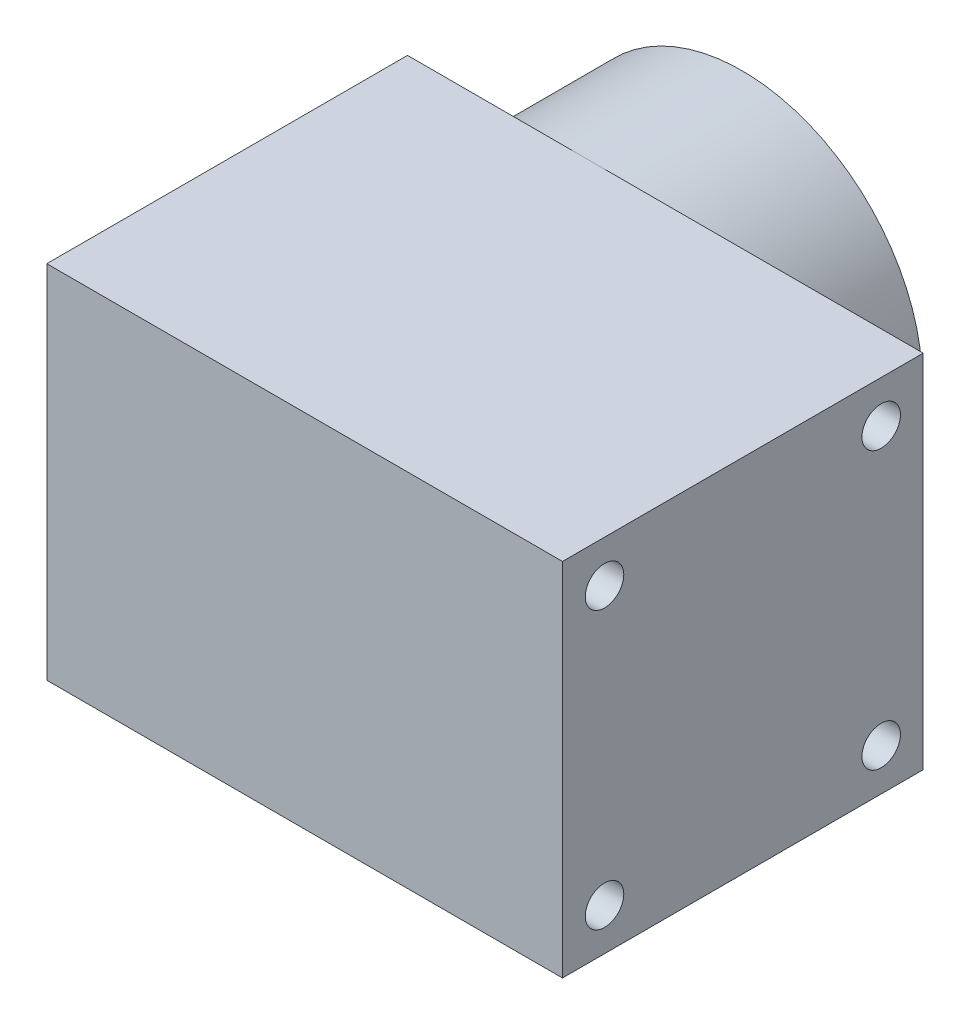
from build123d import *

# Parameters (mm, degrees)
SKETCH1_R           = 28.1
BOSS_EXTRUDE2_DEPTH = 24
CUT_EXTRUDE2_DEPTH  = 21.5
SKETCH4_R           = 3
CUT_EXTRUDE3_DEPTH  = 9.5
SKETCH6_R           = 6.025
CUT_EXTRUDE4_DEPTH  = 6.2
SKETCH7_W           = 56.2
SKETCH7_H           = 56.2
BOSS_EXTRUDE3_DEPTH = 56.2
SKETCH8_W           = 56.2
SKETCH8_H           = 56.2
BOSS_EXTRUDE4_DEPTH = 14.14
SKETCH10_W          = 56.2
SKETCH10_H          = 56.2
BOSS_EXTRUDE5_DEPTH = 10
SKETCH19_W          = 51.2
SKETCH19_H          = 51.2
CUT_EXTRUDE5_DEPTH  = 63.7
SKETCH21_R          = 3
CUT_EXTRUDE7_DEPTH  = 20


with BuildPart() as part:
    # Sketch1 → Boss-Extrude2 (new body)
    with BuildSketch(Plane.XY):
        Circle(SKETCH1_R)
    extrude(amount=BOSS_EXTRUDE2_DEPTH)

    # Sketch3 → Cut-Extrude2 (cut)
    with BuildSketch(Plane(origin=(0, 0, 0), x_dir=(-1, 0, 0), z_dir=(0, 0, -1))):
        with BuildLine():
            Line((-1.661801922, 2.5), (1.661801922, 2.5))
            ThreePointArc((1.661801922, 2.5), (0, -3.001930317), (-1.661801922, 2.5))
        make_face()
    extrude(amount=-CUT_EXTRUDE2_DEPTH, mode=Mode.SUBTRACT)

    # Sketch4 → Cut-Extrude3 (cut)
    with BuildSketch(Plane(origin=(0, 0, 0), x_dir=(-1, 0, 0), z_dir=(0, 0, -1))):
        Circle(SKETCH4_R)
    extrude(amount=-CUT_EXTRUDE3_DEPTH, mode=Mode.SUBTRACT)

    # Sketch6 → Cut-Extrude4 (cut)
    with BuildSketch(Plane(origin=(0, 0, 0), x_dir=(-1, 0, 0), z_dir=(0, 0, -1))):
        Circle(SKETCH6_R)
    extrude(amount=-CUT_EXTRUDE4_DEPTH, mode=Mode.SUBTRACT)

    # Sketch7 → Boss-Extrude3 (add)
    with BuildSketch(Plane.XY.offset(24)):
        Rectangle(SKETCH7_W, SKETCH7_H)
    extrude(amount=BOSS_EXTRUDE3_DEPTH)

    # Sketch8 → Boss-Extrude4 (add)
    with BuildSketch(Plane(origin=(28.1, 0, 0), x_dir=(0, 0, -1), z_dir=(1, 0, 0))):
        with Locations((-52.1, 0)):
            Rectangle(SKETCH8_W, SKETCH8_H)
    extrude(amount=BOSS_EXTRUDE4_DEPTH)

    # Sketch10 → Boss-Extrude5 (add)
    with BuildSketch(Plane(origin=(42.24, 0, 0), x_dir=(0, 0, -1), z_dir=(1, 0, 0))):
        with Locations((-52.1, 0)):
            Rectangle(SKETCH10_W, SKETCH10_H)
    extrude(amount=BOSS_EXTRUDE5_DEPTH)

    # Sketch19 → Cut-Extrude5 (cut)
    with BuildSketch(Plane.ZY.offset(28.1)):
        with Locations((52.1, 0)):
            Rectangle(SKETCH19_W, SKETCH19_H)
    extrude(amount=-CUT_EXTRUDE5_DEPTH, mode=Mode.SUBTRACT)

    # Cut-Sweep2: sweep along a path in Sketch20
    with BuildLine(Plane(origin=(0, 0, 0), x_dir=(-1, 0, 0), z_dir=(0, 0, -1))) as cut_sweep2_path:
        ThreePointArc((0, 15), (-10.606601718, 10.606601718), (-15, 0))
    # 3DSketch2 → Cut-Sweep2 (sweep, cut)
    with BuildSketch(Plane(origin=(0, 15, 0), x_dir=(0, 0.17521220324553322, 0.9845306921746249), z_dir=(-1, 0, 0))):
        Polygon((0, 0), (1.314091524, 7.383980191), (42.805237655, 0), (41.491146131, -7.383980191), align=None)
    sweep(path=cut_sweep2_path.line, mode=Mode.SUBTRACT)

    # Sketch21 → Cut-Extrude7 (cut)
    with BuildSketch(Plane(origin=(52.24, 0, 0), x_dir=(0, 0, -1), z_dir=(1, 0, 0))):
        with Locations((-73.65, 21.55)):
            Circle(SKETCH21_R)
        with Locations((-30.55, 21.55)):
            Circle(SKETCH21_R)
        with Locations((-30.55, -21.55)):
            Circle(SKETCH21_R)
        with Locations((-73.65, -21.55)):
            Circle(SKETCH21_R)
    extrude(amount=-CUT_EXTRUDE7_DEPTH, mode=Mode.SUBTRACT)


solid = part.part
